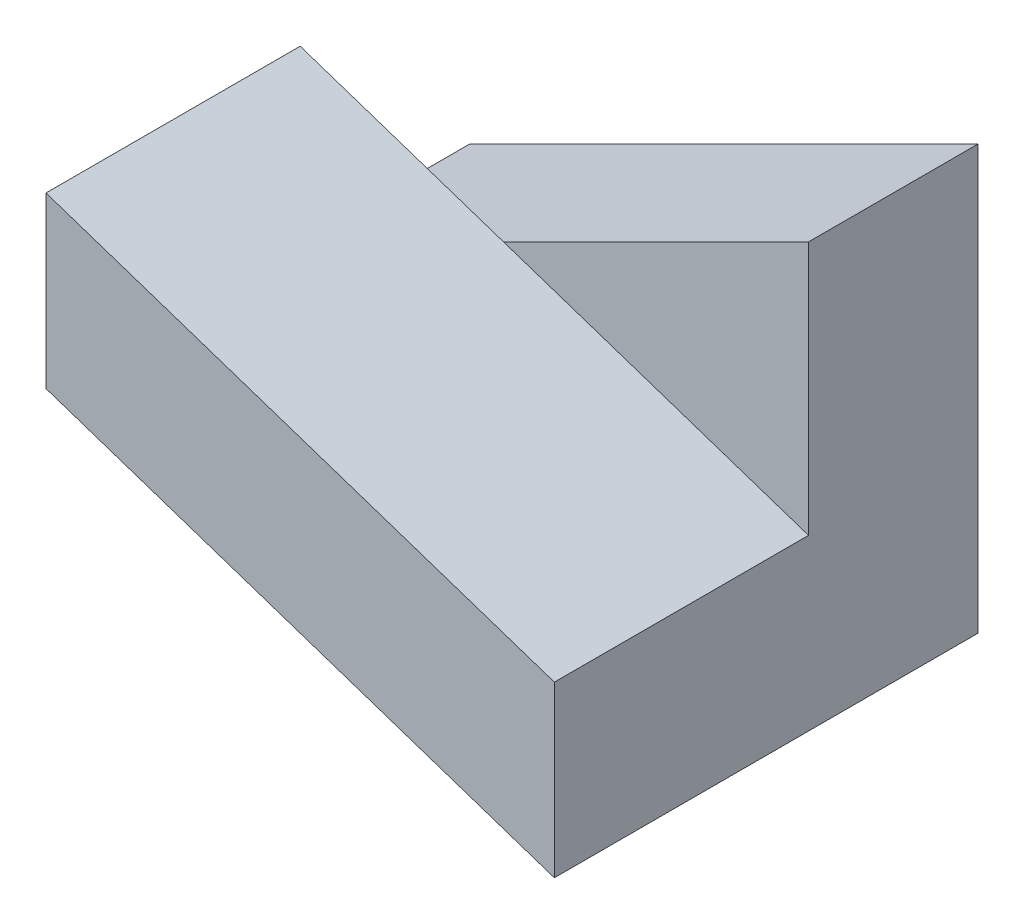
from build123d import *

# Parameters (mm, degrees)
BOSS_EXTRUDE1_DEPTH = 10
BOSS_EXTRUDE4_DEPTH = 15


with BuildPart() as part:
    # Sketch1 → Boss-Extrude1 (new body)
    with BuildSketch(Plane.XY):
        Polygon((0, 0), (-30, 0), (-30, 10), (0, 25), align=None)
    extrude(amount=BOSS_EXTRUDE1_DEPTH)

    # Sketch2 → Boss-Extrude4 (add)
    with BuildSketch(Plane.XY.offset(10)):
        Polygon((-30, 10), (0, 0), (0, 10), (-30, 20), align=None)
    extrude(amount=BOSS_EXTRUDE4_DEPTH)


solid = part.part
